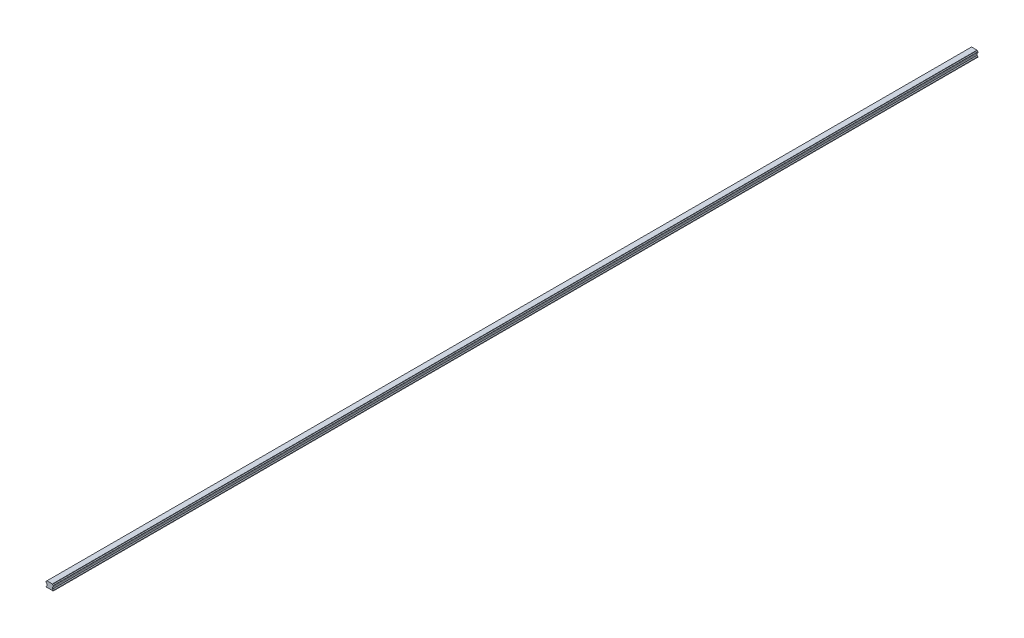
from build123d import *

# Parameters (mm, degrees)
ESTRUSIONE_ESTRUSIONE1_DEPTH = 2897


with BuildPart() as part:
    # Schizzo1 → Estrusione-Estrusione1 (new body)
    with BuildSketch(Plane.XY):
        with BuildLine():
            Line((-10.087089482, -16.415981983), (-7.565622613, -13.894515114))
            Line((-7.565622613, -13.894515114), (-7.565622613, -8.851581376))
            Line((-7.565622613, -8.851581376), (-8.0775657, -8.339638289))
            ThreePointArc((-8.0775657, -8.339638289), (-8.808436534, -6.752953221), (-10.395121602, -6.022082387))
            Line((-10.395121602, -6.022082387), (-10.591382856, -5.825821133))
            Line((-10.591382856, -5.825821133), (-10.591382856, -2.800060891))
            Line((-10.591382856, -2.800060891), (-10.395121602, -2.603799637))
            ThreePointArc((-10.395121602, -2.603799637), (-8.808436534, -1.872928803), (-8.0775657, -0.286243735))
            Line((-8.0775657, -0.286243735), (-7.565622613, 0.225699352))
            Line((-7.565622613, 0.225699352), (9.580352097, 0.225699352))
            Line((9.580352097, 0.225699352), (10.092295184, -0.286243735))
            ThreePointArc((10.092295184, -0.286243735), (10.823166018, -1.872928803), (12.409851086, -2.603799637))
            Line((12.409851086, -2.603799637), (12.606112339, -2.800060891))
            Line((12.606112339, -2.800060891), (12.606112339, -5.825821133))
            Line((12.606112339, -5.825821133), (12.409851086, -6.022082387))
            ThreePointArc((12.409851086, -6.022082387), (10.823166018, -6.752953221), (10.092295184, -8.339638289))
            Line((10.092295184, -8.339638289), (9.580352097, -8.851581376))
            Line((9.580352097, -8.851581376), (9.580352097, -13.894515114))
            Line((9.580352097, -13.894515114), (12.101818966, -16.415981983))
            Line((12.101818966, -16.415981983), (12.101818966, -17.774300648))
            Line((12.101818966, -17.774300648), (-10.087089482, -17.774300648))
            Line((-10.087089482, -17.774300648), (-10.087089482, -16.415981983))
        make_face()
    extrude(amount=ESTRUSIONE_ESTRUSIONE1_DEPTH)


solid = part.part
